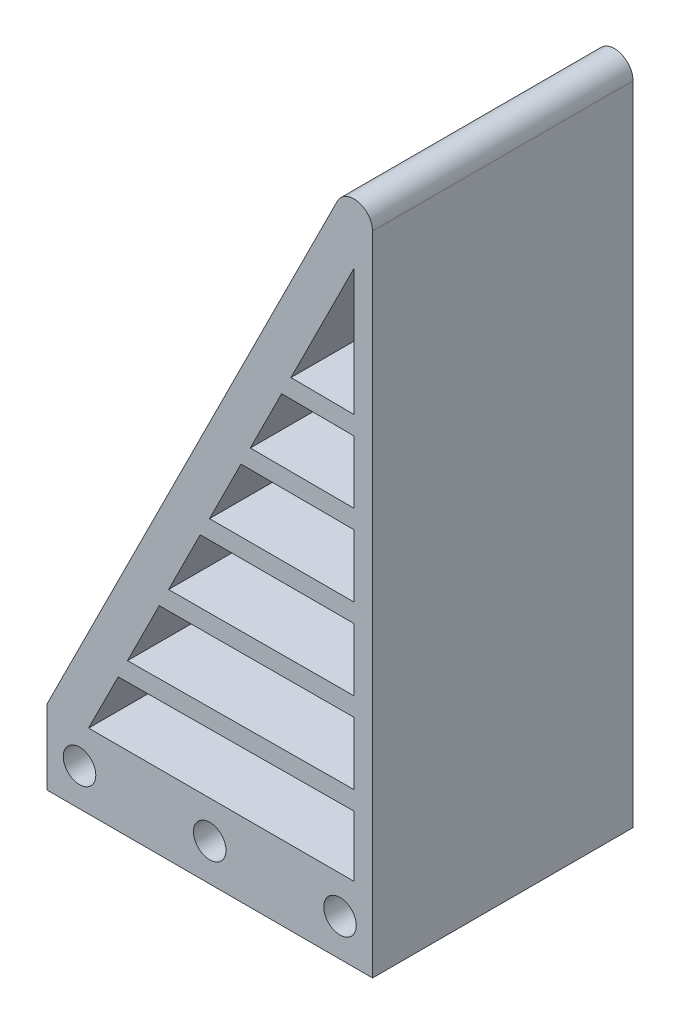
from build123d import *

# Parameters (mm, degrees)
SKETCH_1_W          = 35
SKETCH_1_H          = 8
EXTRUDE_1_DEPTH     = 28
SKETCH_2_R          = 1.75
CUT_EXTRUDE_1_DEPTH = 29
CUT_EXTRUDE_2_DEPTH = 29
FILLET_1_R          = 2
EXTRUDE_2_DEPTH     = 28


with BuildPart() as part:
    # Эскиз1 → Бобышка-Вытянуть1 (new body)
    with BuildSketch(Plane.XY):
        Polygon((17.5, 4), (17.5, 74), (-17.5, 4), align=None)
        Rectangle(SKETCH_1_W, SKETCH_1_H)
    extrude(amount=EXTRUDE_1_DEPTH)

    # Эскиз2 → Вырез-Вытянуть1 (cut, through all)
    with BuildSketch(Plane.XY.offset(28)):
        Circle(SKETCH_2_R)
        with Locations((-14, 0)):
            Circle(SKETCH_2_R)
        with Locations((14, 0)):
            Circle(SKETCH_2_R)
    extrude(amount=-CUT_EXTRUDE_1_DEPTH, mode=Mode.SUBTRACT)

    # Эскиз3 → Вырез-Вытянуть2 (cut, through all)
    with BuildSketch(Plane.XY.offset(28)):
        Polygon((-13.027864045, 4), (15.5, 4), (15.5, 61.05572809), align=None)
    extrude(amount=-CUT_EXTRUDE_2_DEPTH, mode=Mode.SUBTRACT)

    # Скругление1
    fillet_1_edges = [part.edges().sort_by_distance(p)[0] for p in [
        (17.5, 74, 14),
    ]]
    fillet(fillet_1_edges, radius=FILLET_1_R)

    # Эскиз5 → Бобышка-Вытянуть2 (add)
    with BuildSketch(Plane.XY.offset(28)):
        Polygon((15.5, 12.539466863), (15.5, 10.539418123), (-9.84663286, 10.362462369), (-8.843105462, 12.369517166), align=None)
        Polygon((15.5, 21.269833716), (15.5, 19.269821531), (-5.429482266, 19.196763559), (-4.427727775, 21.200272541), align=None)
        Polygon((-0.027864045, 30), (-1.027864045, 28), (15.5, 28), (15.5, 30), align=None)
        Polygon((4.356674041, 38.769076173), (3.358410255, 36.7725486), (15.5, 36.730166284), (15.5, 38.730178469), align=None)
        Polygon((8.726072744, 47.507873578), (7.729527032, 45.514782153), (15.5, 45.460533137), (15.5, 47.460581877), align=None)
    extrude(amount=-EXTRUDE_2_DEPTH)


solid = part.part
